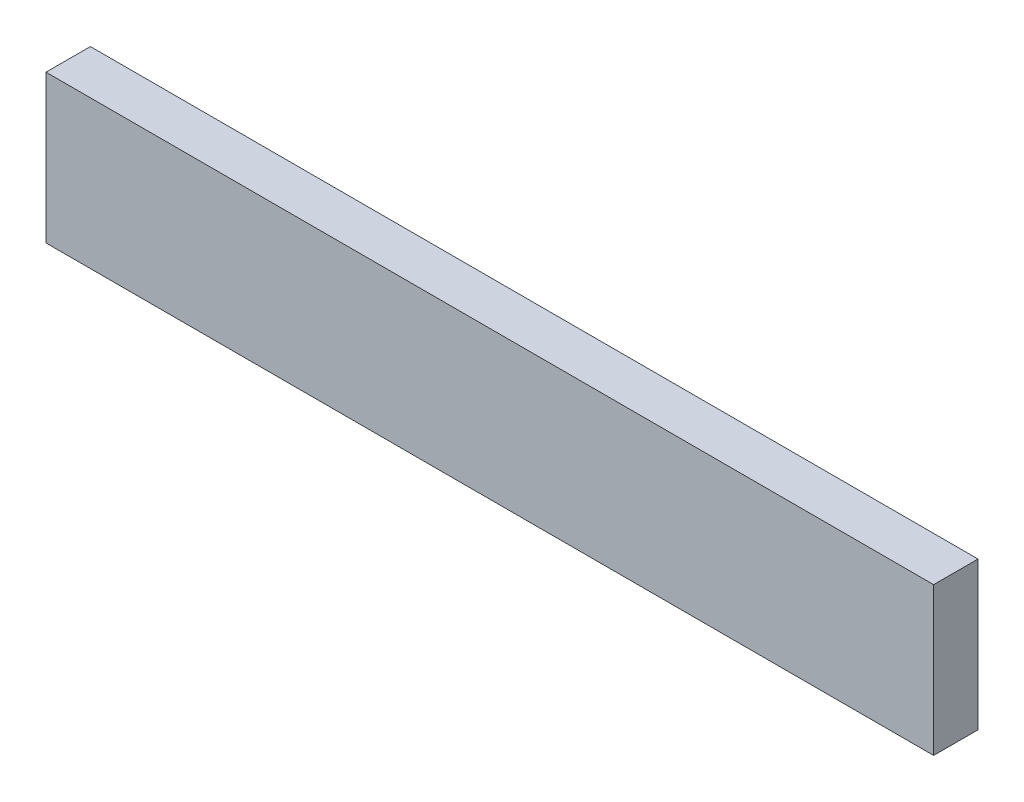
from build123d import *

# Parameters (mm, degrees)
CROQUIS1_W              = 152.4
CROQUIS1_H              = 25.4
SALIENTE_EXTRUIR1_DEPTH = 7.62


with BuildPart() as part:
    # Croquis1 → Saliente-Extruir1 (new body)
    with BuildSketch(Plane.XY):
        with Locations((-2.036077634, 32.702823503)):
            Rectangle(CROQUIS1_W, CROQUIS1_H)
    extrude(amount=SALIENTE_EXTRUIR1_DEPTH)


solid = part.part
